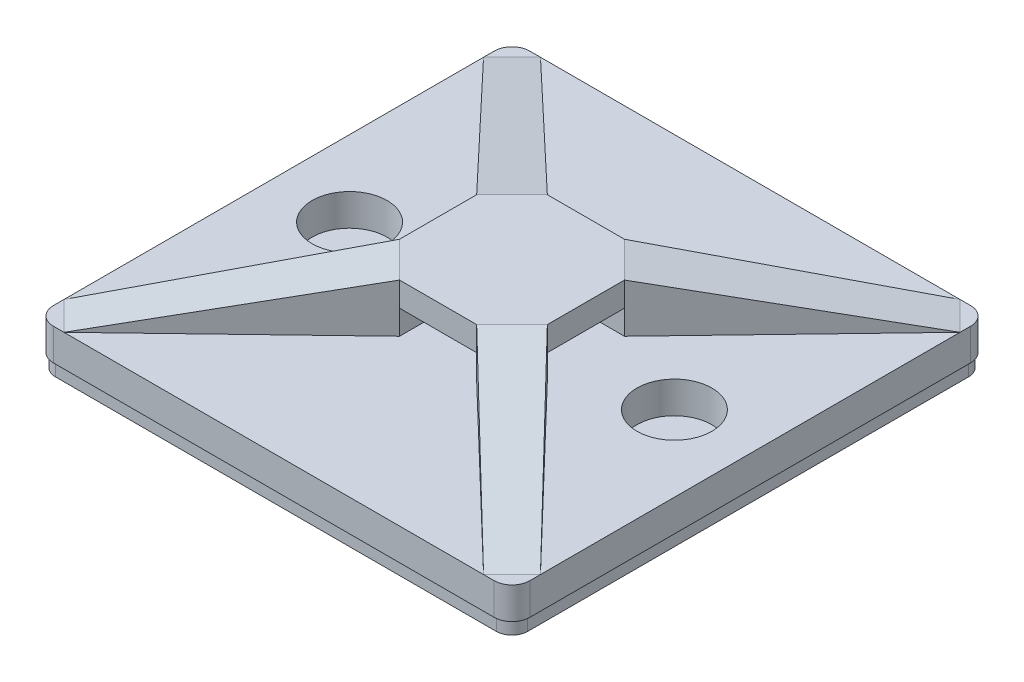
from build123d import *

# Parameters (mm, degrees)
BOSS_EXTRUDE1_DEPTH   = 1.905
BOSS_EXTRUDE2_DEPTH   = 2.921
CUT_EXTRUDE2_DEPTH    = 21.773916061
CIRPATTERN3_COUNT     = 4
SKETCH5_W             = 4.62591911
SKETCH5_H             = 1.4605
CUT_EXTRUDE3_DEPTH    = 25.03859073
CIRPATTERN4_COUNT     = 4
F_8_CLEARANCE_HOLE1_D = 4.4958
BOSS_EXTRUDE3_DEPTH   = 0.79375


with BuildPart() as part:
    # Sketch1 → Boss-Extrude1 (new body)
    with BuildSketch(Plane(origin=(0, 0, 0), x_dir=(1, 0, 0), z_dir=(0, 1, 0))):
        with BuildLine():
            Line((13.2207, -14.2875), (-13.2207, -14.2875))
            ThreePointArc((-13.2207, -14.2875), (-13.975041514, -13.975041514), (-14.2875, -13.2207))
            Line((-14.2875, -13.2207), (-14.2875, 13.2207))
            ThreePointArc((-14.2875, 13.2207), (-13.975041514, 13.975041514), (-13.2207, 14.2875))
            Line((-13.2207, 14.2875), (13.2207, 14.2875))
            ThreePointArc((13.2207, 14.2875), (13.975041514, 13.975041514), (14.2875, 13.2207))
            Line((14.2875, 13.2207), (14.2875, -13.2207))
            ThreePointArc((14.2875, -13.2207), (13.975041514, -13.975041514), (13.2207, -14.2875))
        make_face()
    extrude(amount=BOSS_EXTRUDE1_DEPTH)

    # Sketch2 → Boss-Extrude2 (add)
    with BuildSketch(Plane(origin=(0, 1.905, 0), x_dir=(1, 0, 0), z_dir=(0, 1, 0))):
        Polygon((4.4323, -2.312959555), (4.4323, 2.312959555), (14.2875, 12.581251337), (12.581251337, 14.2875), (2.312959555, 4.4323), (-2.312959555, 4.4323), (-12.581251337, 14.2875), (-14.2875, 12.581251337), (-4.4323, 2.312959555), (-4.4323, -2.312959555), (-14.2875, -12.581251337), (-12.581251337, -14.2875), (-2.312959555, -4.4323), (2.312959555, -4.4323), (12.581251337, -14.2875), (14.2875, -12.581251337), align=None)
    extrude(amount=BOSS_EXTRUDE2_DEPTH)

    # Sketch4 → Cut-Extrude2 (cut, symmetric)
    with BuildSketch(Plane(origin=(0, 0, 0), x_dir=(0, -1, 0), z_dir=(0.7071067811865488, 0, 0.7071067811865464))):
        Polygon((-4.826, 4.769618773), (-1.905, 18.999076272), (-4.826, 18.999076272), align=None)
    cut_extrude2 = extrude(amount=CUT_EXTRUDE2_DEPTH, both=True, mode=Mode.SUBTRACT)

    # CirPattern3: Cut-Extrude2 ×4 about axis
    cirpattern3_axis = Axis((0, 5.0673, 0), (0, -1, 0))
    for i in range(1, CIRPATTERN3_COUNT):
        add(cut_extrude2.rotate(cirpattern3_axis, i * 360 / CIRPATTERN3_COUNT), mode=Mode.SUBTRACT)

    # Sketch5 → Cut-Extrude3 (cut, through all)
    with BuildSketch(Plane.XY.offset(4.4323)):
        with Locations((0, 2.63525)):
            Rectangle(SKETCH5_W, SKETCH5_H)
    cut_extrude3 = extrude(amount=-CUT_EXTRUDE3_DEPTH, mode=Mode.SUBTRACT)

    # CirPattern4: Cut-Extrude3 ×4 about axis
    cirpattern4_axis = Axis((0, 5.0673, 0), (0, -1, 0))
    for i in range(1, CIRPATTERN4_COUNT):
        add(cut_extrude3.rotate(cirpattern4_axis, i * 360 / CIRPATTERN4_COUNT), mode=Mode.SUBTRACT)

    # 8 Clearance Hole1 (through all)
    with Locations(Plane(origin=(0, 1.905, 0), x_dir=(1, 0, 0), z_dir=(0, 1, 0))):
        with Locations((-9.7409, 0), (9.7409, 0)):
            Hole(F_8_CLEARANCE_HOLE1_D / 2)

    # Sketch6 → Boss-Extrude3 (add)
    with BuildSketch(Plane.XZ):
        with BuildLine():
            Line((-14.1605, 13.2207), (-14.1605, -13.2207))
            ThreePointArc((-14.1605, -13.2207), (-13.885238953, -13.885238953), (-13.2207, -14.1605))
            Line((-13.2207, -14.1605), (13.2207, -14.1605))
            ThreePointArc((13.2207, -14.1605), (13.885238953, -13.885238953), (14.1605, -13.2207))
            Line((14.1605, -13.2207), (14.1605, 13.2207))
            ThreePointArc((14.1605, 13.2207), (13.885238953, 13.885238953), (13.2207, 14.1605))
            Line((13.2207, 14.1605), (-13.2207, 14.1605))
            ThreePointArc((-13.2207, 14.1605), (-13.885238953, 13.885238953), (-14.1605, 13.2207))
        make_face()
    extrude(amount=BOSS_EXTRUDE3_DEPTH)


solid = part.part
